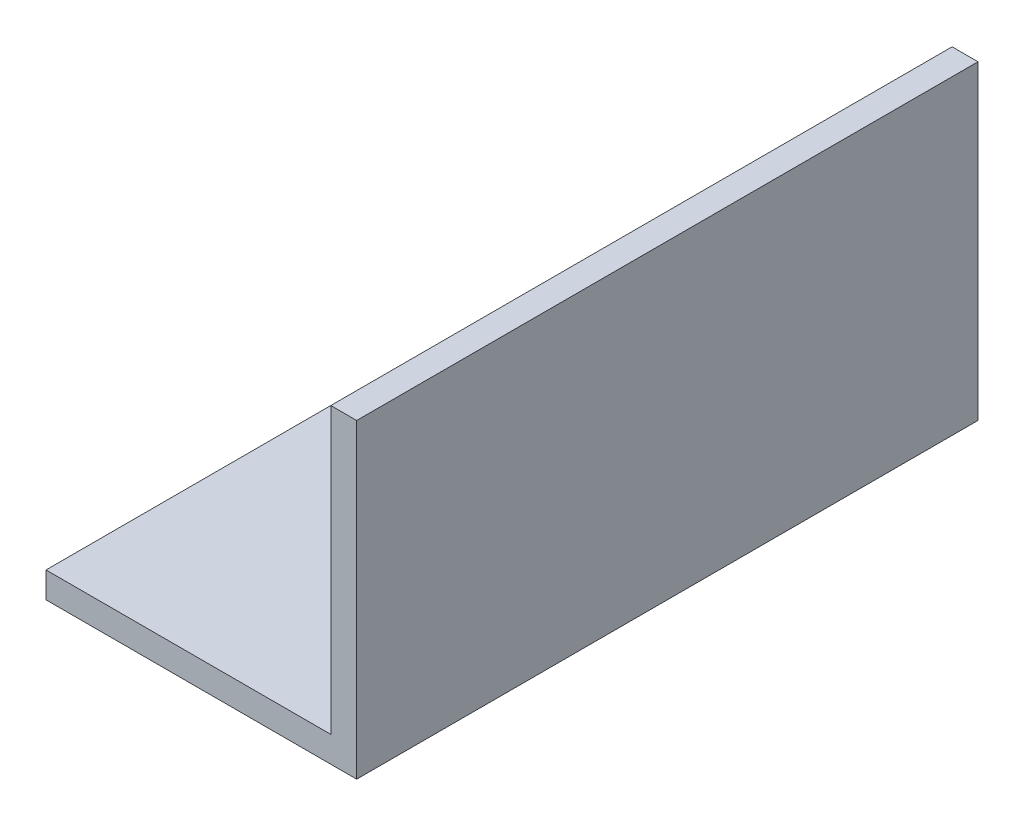
from build123d import *

# Parameters (mm, degrees)
BOSS_EXTRUDE1_DEPTH = 38.1
CUT_EXTRUDE1_REACH  = 5.175
SKETCH3_R           = 4.365625


with BuildPart() as part:
    # Sketch1 → Boss-Extrude1 (new body, symmetric)
    with BuildSketch(Plane(origin=(0, 0, 0), x_dir=(0, -1, 0), z_dir=(0, 0, 1))):
        Polygon((0, 0), (-38.1, 0), (-38.1, -3.175), (-3.175, -3.175), (-3.175, -38.1), (0, -38.1), align=None)
    extrude(amount=BOSS_EXTRUDE1_DEPTH, both=True)

    # Sketch3 → Cut-Extrude1 (cut, up to next)
    with BuildSketch(Plane(origin=(0, 3.175, 0), x_dir=(1, 0, 0), z_dir=(0, 1, 0)), mode=Mode.PRIVATE) as cut_extrude1_sk1:
        with Locations(Location((-25.4, 0, 0), (0, 0, 180))):  # turned: the seam where the file's is
            Circle(SKETCH3_R)
    cut_extrude1_tool1 = extrude(cut_extrude1_sk1.sketch, amount=-CUT_EXTRUDE1_REACH, mode=Mode.PRIVATE) & part.part
    add(cut_extrude1_tool1.solids().sort_by_distance((-25.4, 3.175, 0))[0], mode=Mode.SUBTRACT)


solid = part.part
